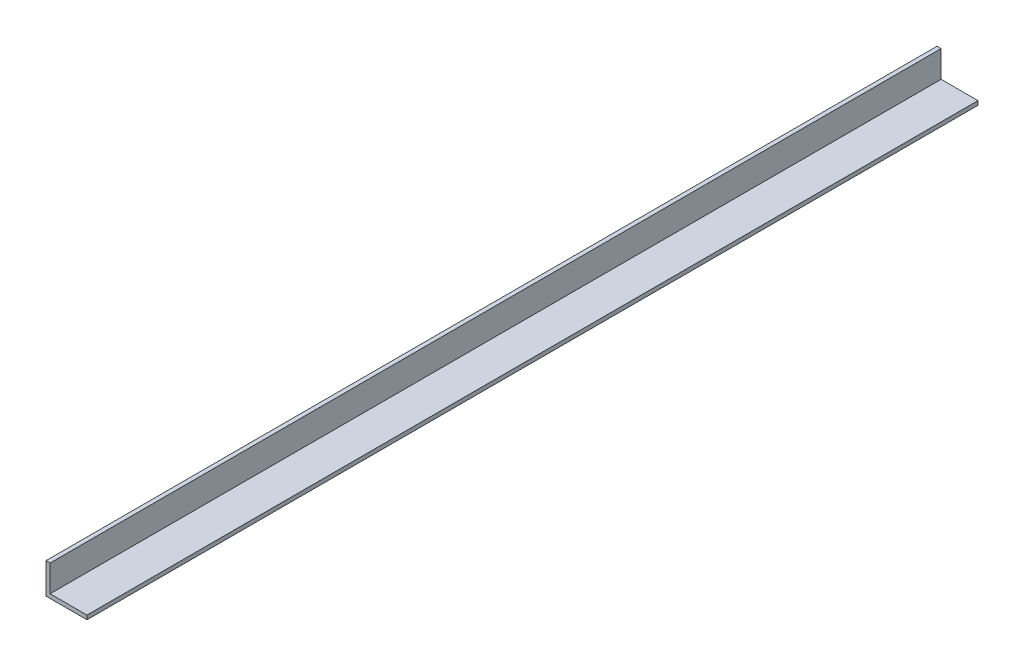
from build123d import *

# Parameters (mm, degrees)
EXTRUDE_1_DEPTH = 217.5


with BuildPart() as part:
    # 草图1 → 凸台-拉伸1 (new body, symmetric)
    with BuildSketch(Plane.XY):
        Polygon((0, 15), (0, 0), (20, 0), (20, 2), (2, 2), (2, 15), align=None)
    extrude(amount=EXTRUDE_1_DEPTH, both=True)


solid = part.part
